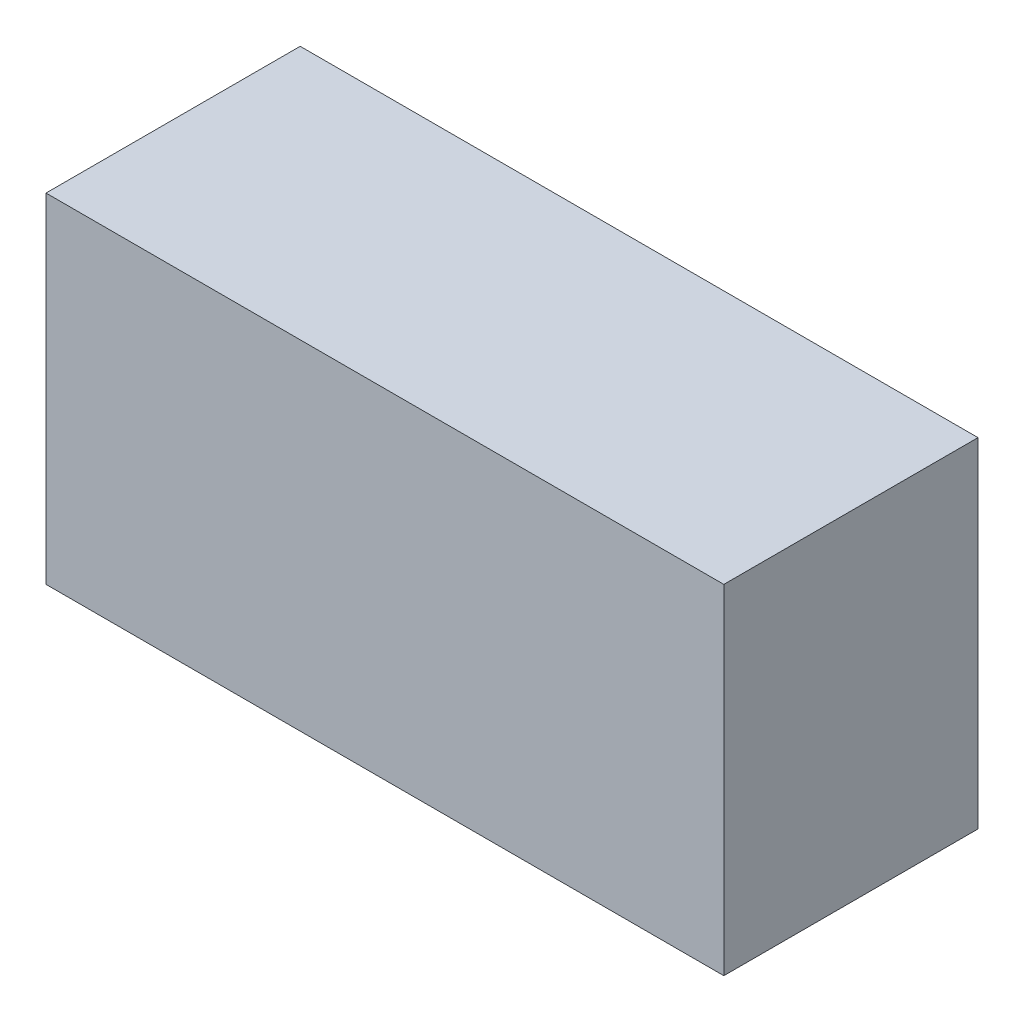
from build123d import *

# Parameters (mm, degrees)
SKETCH2_W           = 40
SKETCH2_H           = 20
BOSS_EXTRUDE1_DEPTH = 15


with BuildPart() as part:
    # Sketch2 → Boss-Extrude1 (new body)
    with BuildSketch(Plane.XY):
        Rectangle(SKETCH2_W, SKETCH2_H)
    extrude(amount=BOSS_EXTRUDE1_DEPTH)


solid = part.part
